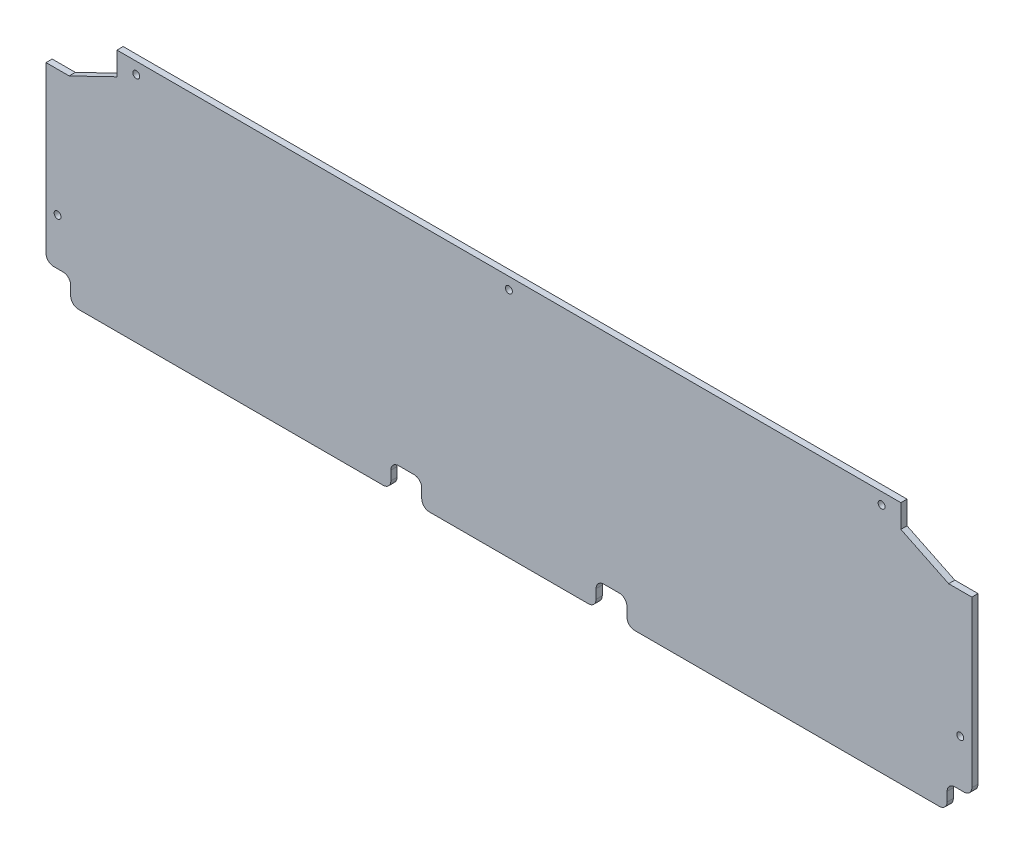
from build123d import *

# Parameters (mm, degrees)
SKETCH_1_W          = 600
SKETCH_1_H          = 158
EXTRUDE_1_DEPTH     = 4
SKETCH_2_W          = 20
SKETCH_2_H          = 16
SKETCH_2_W_2        = 16
CUT_EXTRUDE_1_DEPTH = 10
FILLET_1_R          = 5
HOLE_WIZARD_M4_1_D  = 4.5


with BuildPart() as part:
    # ｽｹｯﾁ1 → ﾎﾞｽ - 押し出し1 (new body)
    with BuildSketch(Plane.XY):
        with Locations((300, 79)):
            Rectangle(SKETCH_1_W, SKETCH_1_H)
    extrude(amount=EXTRUDE_1_DEPTH)

    # ｽｹｯﾁ2 → ｶｯﾄ - 押し出し1 (cut)
    with BuildSketch(Plane.XY.offset(4)):
        Polygon((46, 158), (46, 143), (15, 128), (0, 128), (0, 158), align=None)
        Polygon((600, 158), (600, 128), (585, 128), (554, 143), (554, 158), align=None)
        with Locations((366.5, 8)):
            Rectangle(SKETCH_2_W, SKETCH_2_H)
        with Locations((8, 8)):
            Rectangle(SKETCH_2_W_2, SKETCH_2_H)
        with Locations((233.5, 8)):
            Rectangle(SKETCH_2_W, SKETCH_2_H)
        with Locations((592, 8)):
            Rectangle(SKETCH_2_W_2, SKETCH_2_H)
    extrude(amount=-CUT_EXTRUDE_1_DEPTH, mode=Mode.SUBTRACT)

    # ﾌｨﾚｯﾄ1
    fillet_1_edges = [part.edges().sort_by_distance(p)[0] for p in [
        (376.5, 0, 2),
        (356.5, 0, 2),
        (356.5, 16, 2),
        (376.5, 16, 2),
        (223.5, 0, 2),
        (223.5, 16, 2),
        (243.5, 16, 2),
        (243.5, 0, 2),
        (0, 16, 2),
        (16, 16, 2),
        (16, 0, 2),
        (584, 16, 2),
        (600, 16, 2),
        (584, 0, 2),
    ]]
    fillet(fillet_1_edges, radius=FILLET_1_R)

    # M4 すきま穴1 (through all)
    with Locations(Plane.XY.offset(4)):
        with Locations((58.5, 150.5), (300, 150.5), (541.5, 150.5), (592.5, 46.18), (7.5, 46.18)):
            Hole(HOLE_WIZARD_M4_1_D / 2)


solid = part.part
